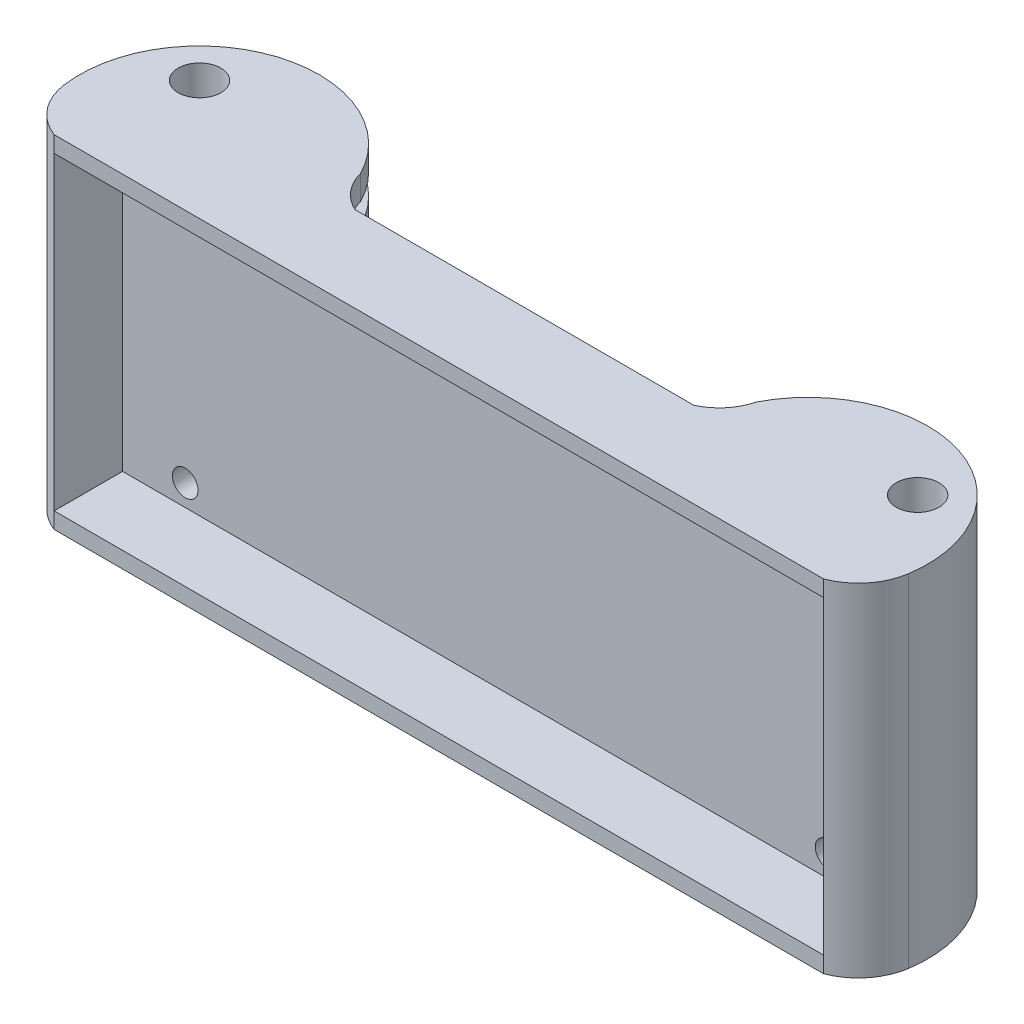
from build123d import *

# Parameters (mm, degrees)
SKETCH1_R           = 2.5
BOSS_EXTRUDE2_DEPTH = 40
SKETCH3_W           = 90
SKETCH3_H           = 36.22
SKETCH3_R           = 1.5
SKETCH3_W_2         = 40
SKETCH3_H_2         = 2.46
CUT_EXTRUDE1_DEPTH  = 8
SKETCH3_5_W         = 40
SKETCH3_5_H         = 2.46
SKETCH3_5_R         = 1.5
CUT_EXTRUDE3_DEPTH  = 68.275313507


with BuildPart() as part:
    # Sketch1 → Boss-Extrude2 (new body)
    with BuildSketch(Plane(origin=(0, 0, 0), x_dir=(1, 0, 0), z_dir=(0, 1, 0))):
        with BuildLine():
            Line((-45, -14), (45, -14))
            ThreePointArc((45, -14), (47.968786967, -11.849318779), (49.443427998, -8.493047098))
            ThreePointArc((49.443427998, -8.493047098), (39.902505959, 6.907779255), (23.154454386, 0))
            ThreePointArc((23.154454386, 0), (21.939767311, -2.382145151), (19.810770857, -4))
            Line((19.810770857, -4), (-19.810770857, -4))
            ThreePointArc((-19.810770857, -4), (-21.939767311, -2.382145151), (-23.154454386, 0))
            ThreePointArc((-23.154454386, 0), (-39.902505959, 6.907779255), (-49.443427998, -8.493047098))
            ThreePointArc((-49.443427998, -8.493047098), (-47.968786967, -11.849318779), (-45, -14))
        make_face()
        with Locations((-42, 0)):
            Circle(SKETCH1_R, mode=Mode.SUBTRACT)
        with Locations((42, 0)):
            Circle(SKETCH1_R, mode=Mode.SUBTRACT)
    extrude(amount=BOSS_EXTRUDE2_DEPTH)

    # Sketch3 → Cut-Extrude1 (cut)
    with BuildSketch(Plane.XY.offset(14)):
        with Locations((0, 20)):
            Rectangle(SKETCH3_W, SKETCH3_H)
        with Locations((-37.672430774, 4.382060635)):
            Circle(SKETCH3_R, mode=Mode.SUBTRACT)
        with Locations((37.527569226, 4.382060635)):
            Circle(SKETCH3_R, mode=Mode.SUBTRACT)
        with Locations((-37.672430774, 35.802060635)):
            Circle(SKETCH3_R, mode=Mode.SUBTRACT)
        with Locations((-15.072430774, 35.917939365)):
            Rectangle(SKETCH3_W_2, SKETCH3_H_2, mode=Mode.SUBTRACT)
        with Locations((37.527569226, 35.802060635)):
            Circle(SKETCH3_R, mode=Mode.SUBTRACT)
    extrude(amount=-CUT_EXTRUDE1_DEPTH, mode=Mode.SUBTRACT)

    # Sketch3_5 → Cut-Extrude3 (cut, through all)
    with BuildSketch(Plane.XY.offset(14)):
        with Locations((-15.072430774, 35.917939365)):
            Rectangle(SKETCH3_5_W, SKETCH3_5_H)
        with Locations((37.527569226, 35.802060635)):
            Circle(SKETCH3_5_R)
        with Locations((-37.672430774, 35.802060635)):
            Circle(SKETCH3_5_R)
        with Locations((-37.672430774, 4.382060635)):
            Circle(SKETCH3_5_R)
        with Locations((37.527569226, 4.382060635)):
            Circle(SKETCH3_5_R)
    extrude(amount=-CUT_EXTRUDE3_DEPTH, mode=Mode.SUBTRACT)


solid = part.part
